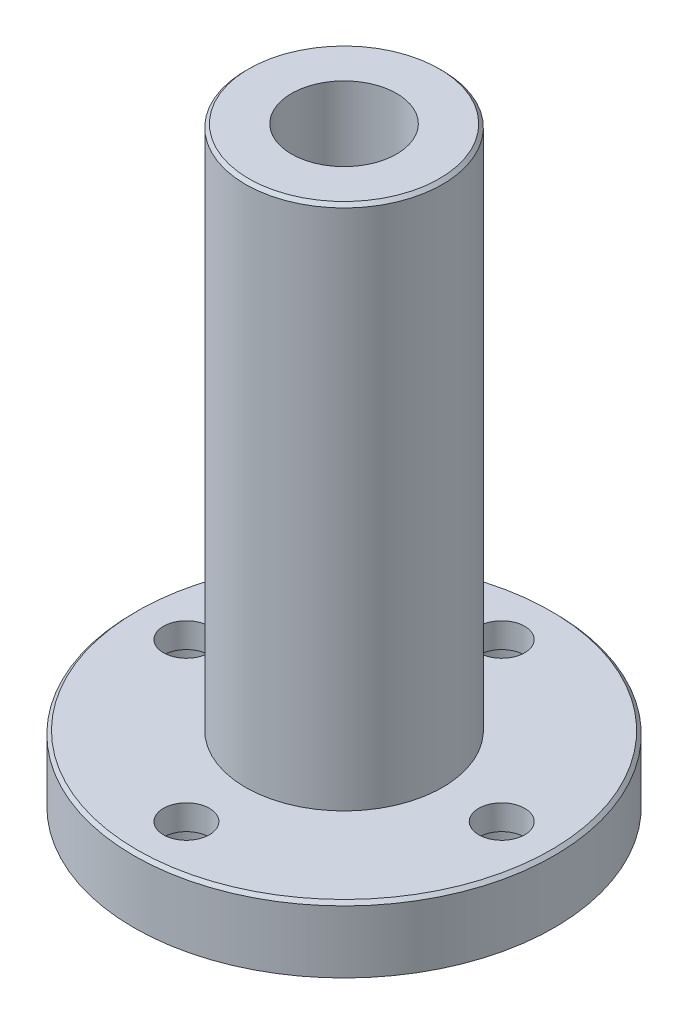
from build123d import *

# Parameters (mm, degrees)
SKETCH1_R           = 16
BOSS_EXTRUDE3_DEPTH = 5
SKETCH4_R           = 7.5
BOSS_EXTRUDE4_DEPTH = 40
SKETCH5_R           = 1.75
CUT_EXTRUDE2_DEPTH  = 5
SKETCH6_R           = 4
CUT_EXTRUDE3_DEPTH  = 45
SKETCH7_R           = 3
CUT_EXTRUDE4_DEPTH  = 3.1
CHAMFER1_SIZE       = 0.25


with BuildPart() as part:
    # Sketch1 → Boss-Extrude3 (new body)
    with BuildSketch(Plane(origin=(0, 0, 0), x_dir=(1, 0, 0), z_dir=(0, 1, 0))):
        Circle(SKETCH1_R)
    extrude(amount=BOSS_EXTRUDE3_DEPTH)

    # Sketch4 → Boss-Extrude4 (add)
    with BuildSketch(Plane(origin=(0, 5, 0), x_dir=(1, 0, 0), z_dir=(0, 1, 0))):
        Circle(SKETCH4_R)
    extrude(amount=BOSS_EXTRUDE4_DEPTH)

    # Sketch5 → Cut-Extrude2 (cut)
    with BuildSketch(Plane(origin=(0, 5, 0), x_dir=(1, 0, 0), z_dir=(0, 1, 0))):
        with Locations((0, 12)):
            Circle(SKETCH5_R)
        with Locations((-12, 0)):
            Circle(SKETCH5_R)
        with Locations((12, 0)):
            Circle(SKETCH5_R)
        with Locations((0, -12)):
            Circle(SKETCH5_R)
    extrude(amount=-CUT_EXTRUDE2_DEPTH, mode=Mode.SUBTRACT)

    # Sketch6 → Cut-Extrude3 (cut)
    with BuildSketch(Plane(origin=(0, 45, 0), x_dir=(1, 0, 0), z_dir=(0, 1, 0))):
        Circle(SKETCH6_R)
    extrude(amount=-CUT_EXTRUDE3_DEPTH, mode=Mode.SUBTRACT)

    # Sketch7 → Cut-Extrude4 (cut)
    with BuildSketch(Plane.XZ):
        with Locations((0, 12)):
            Circle(SKETCH7_R)
        with Locations((-12, 0)):
            Circle(SKETCH7_R)
        with Locations((0, -12)):
            Circle(SKETCH7_R)
        with Locations((12, 0)):
            Circle(SKETCH7_R)
    extrude(amount=-CUT_EXTRUDE4_DEPTH, mode=Mode.SUBTRACT)

    # Chamfer1
    chamfer1_edges = [part.edges().sort_by_distance(p)[0] for p in [
        (-16, 5, 0),
        (-7.5, 45, 0),
    ]]
    chamfer(chamfer1_edges, length=CHAMFER1_SIZE)


solid = part.part
